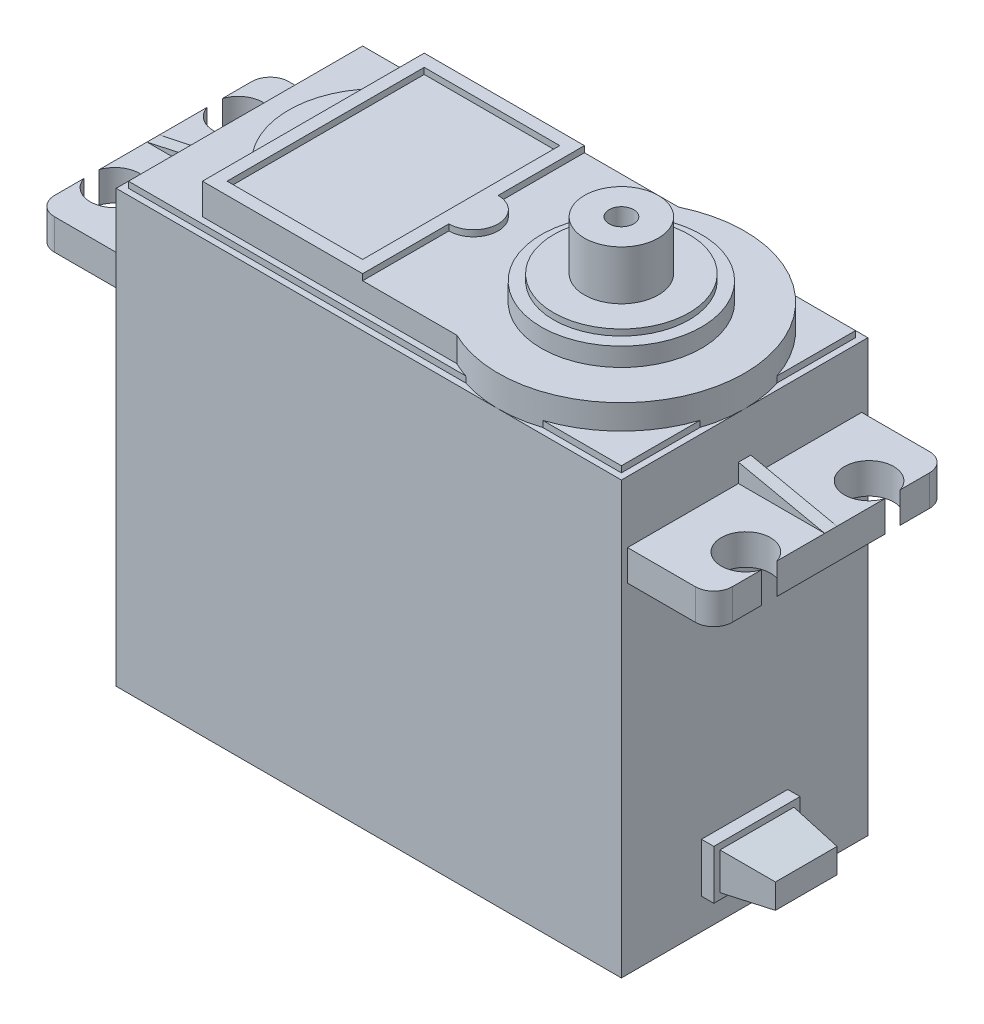
from build123d import *

# Parameters (mm, degrees)
SKETCH1_W            = 41
SKETCH1_H            = 20
BOSS_EXTRUDE1_DEPTH  = 40
CHAMFER1_SIZE        = 2
SKETCH2_R            = 2.25
CUT_EXTRUDE1_DEPTH   = 1
SKETCH3_W            = 19
SKETCH3_H            = 2.5
BOSS_EXTRUDE2_DEPTH  = 7
FILLET1_R            = 1.5
SKETCH4_W            = 7
SKETCH4_H            = 1
BOSS_EXTRUDE3_DEPTH  = 1.5
CUT_EXTRUDE2_DEPTH   = 1
SKETCH6_R            = 2
CUT_EXTRUDE3_DEPTH   = 2.5
FILLET1_OF_MIRROR1_R = 1.5
SKETCH7_W            = 41
SKETCH7_H            = 20
CUT_EXTRUDE4_DEPTH   = 3
SKETCH8_W            = 40
SKETCH8_H            = 19
BOSS_EXTRUDE4_DEPTH  = 0.5
BOSS_EXTRUDE6_DEPTH  = 2.5
SKETCH10_W           = 11
SKETCH10_H           = 16
BOSS_EXTRUDE7_DEPTH  = 0.5
SKETCH11_R           = 6.5
BOSS_EXTRUDE8_DEPTH  = 1.5
SKETCH12_R           = 5.5
BOSS_EXTRUDE9_DEPTH  = 0.5
SKETCH13_R           = 3
BOSS_EXTRUDE10_DEPTH = 4
SKETCH14_R           = 1
CUT_EXTRUDE5_DEPTH   = 8
SKETCH15_W           = 7
SKETCH15_H           = 4
BOSS_EXTRUDE11_DEPTH = 5
SKETCH16_W           = 7
SKETCH16_H           = 4
SKETCH16_W_2         = 6
SKETCH16_H_2         = 3
CUT_EXTRUDE6_DEPTH   = 4
CUT_EXTRUDE7_DEPTH   = 3
CUT_EXTRUDE8_DEPTH   = 7


with BuildPart() as part:
    # Sketch1 → Boss-Extrude1 (new body)
    with BuildSketch(Plane(origin=(0, 0, 0), x_dir=(1, 0, 0), z_dir=(0, 1, 0))):
        Rectangle(SKETCH1_W, SKETCH1_H)
    extrude(amount=BOSS_EXTRUDE1_DEPTH)

    # Chamfer1
    chamfer1_edges = [part.edges().sort_by_distance(p)[0] for p in [
        (0, 0, 10),
        (-20.5, 0, 0),
        (0, 0, -10),
        (20.5, 0, 0),
    ]]
    chamfer(chamfer1_edges, length=CHAMFER1_SIZE)

    # Sketch2 → Cut-Extrude1 (cut)
    with BuildSketch(Plane.XZ):
        with Locations((18.25, 7.75)):
            Circle(SKETCH2_R)
        with Locations((-18.25, 7.75)):
            Circle(SKETCH2_R)
        with Locations((-18.25, -7.75)):
            Circle(SKETCH2_R)
        with Locations((18.25, -7.75)):
            Circle(SKETCH2_R)
    extrude(amount=-CUT_EXTRUDE1_DEPTH, mode=Mode.SUBTRACT)

    # Sketch3 → Boss-Extrude2 (add)
    with BuildSketch(Plane(origin=(20.5, 0, 0), x_dir=(0, 0, -1), z_dir=(1, 0, 0))):
        with Locations((0, 30.75)):
            Rectangle(SKETCH3_W, SKETCH3_H)
    boss_extrude2 = extrude(amount=BOSS_EXTRUDE2_DEPTH)

    # Fillet1
    fillet1_edges = [part.edges().sort_by_distance(p)[0] for p in [
        (27.5, 30.75, 9.5),
        (27.5, 30.75, -9.5),
    ]]
    fillet(fillet1_edges, radius=FILLET1_R)

    # Sketch4 → Boss-Extrude3 (add)
    with BuildSketch(Plane(origin=(0, 32, 0), x_dir=(1, 0, 0), z_dir=(0, 1, 0))):
        with Locations((24, 0)):
            Rectangle(SKETCH4_W, SKETCH4_H)
    boss_extrude3 = extrude(amount=BOSS_EXTRUDE3_DEPTH)

    # Sketch5 → Cut-Extrude2 (cut)
    with BuildSketch(Plane.XY.offset(0.5)):
        Polygon((27.5, 33.5), (27.5, 32), (20.5, 33.5), align=None)
    cut_extrude2 = extrude(amount=-CUT_EXTRUDE2_DEPTH, mode=Mode.SUBTRACT)

    # Sketch6 → Cut-Extrude3 (cut)
    with BuildSketch(Plane(origin=(0, 32, 0), x_dir=(1, 0, 0), z_dir=(0, 1, 0))):
        with Locations((25.6, 5)):
            Circle(SKETCH6_R)
        with Locations((25.6, -5)):
            Circle(SKETCH6_R)
    cut_extrude3 = extrude(amount=-CUT_EXTRUDE3_DEPTH, mode=Mode.SUBTRACT)

    # Mirror1: Boss-Extrude2, Boss-Extrude3, Cut-Extrude2, Cut-Extrude3 across plane
    add(boss_extrude2.mirror(Plane(origin=(0, 0, 0), x_dir=(0, 0, 1), z_dir=(1, 0, 0))))
    add(boss_extrude3.mirror(Plane(origin=(0, 0, 0), x_dir=(0, 0, 1), z_dir=(1, 0, 0))))
    add(cut_extrude2.mirror(Plane(origin=(0, 0, 0), x_dir=(0, 0, 1), z_dir=(1, 0, 0))), mode=Mode.SUBTRACT)
    add(cut_extrude3.mirror(Plane(origin=(0, 0, 0), x_dir=(0, 0, 1), z_dir=(1, 0, 0))), mode=Mode.SUBTRACT)

    # Fillet1 of Mirror1
    fillet1_of_mirror1_edges = [part.edges().sort_by_distance(p)[0] for p in [
        (-27.5, 30.75, 9.5),
        (-27.5, 30.75, -9.5),
    ]]
    fillet(fillet1_of_mirror1_edges, radius=FILLET1_OF_MIRROR1_R)

    # Sketch7 → Cut-Extrude4 (cut)
    with BuildSketch(Plane(origin=(0, 40, 0), x_dir=(1, 0, 0), z_dir=(0, 1, 0))):
        Rectangle(SKETCH7_W, SKETCH7_H)
    extrude(amount=-CUT_EXTRUDE4_DEPTH, mode=Mode.SUBTRACT)

    # Sketch8 → Boss-Extrude4 (add)
    with BuildSketch(Plane(origin=(0, 37, 0), x_dir=(1, 0, 0), z_dir=(0, 1, 0))):
        Rectangle(SKETCH8_W, SKETCH8_H)
    extrude(amount=BOSS_EXTRUDE4_DEPTH)

    # Sketch9 → Boss-Extrude6 (add)
    with BuildSketch(Plane(origin=(0, 37, 0), x_dir=(1, 0, 0), z_dir=(0, 1, 0))):
        with BuildLine():
            Line((6.141101056, 9), (-14.5, 9))
            Line((-14.5, 9), (-14.5, 5))
            ThreePointArc((-14.5, 5), (-16.5, 0), (-14.5, -5))
            Line((-14.5, -5), (-14.5, -9))
            Line((-14.5, -9), (6.141101056, -9))
            ThreePointArc((6.141101056, -9), (20.5, 0), (6.141101056, 9))
        make_face()
    extrude(amount=BOSS_EXTRUDE6_DEPTH)

    # Sketch10 → Boss-Extrude7 (add)
    with BuildSketch(Plane(origin=(0, 39.5, 0), x_dir=(1, 0, 0), z_dir=(0, 1, 0))):
        with BuildLine():
            Line((-14.5, 9), (-1.5, 9))
            Line((-1.5, 9), (-1.5, 2))
            ThreePointArc((-1.5, 2), (0.5, 0), (-1.5, -2))
            Line((-1.5, -2), (-1.5, -9))
            Line((-1.5, -9), (-14.5, -9))
            Line((-14.5, -9), (-14.5, 9))
        make_face()
        with Locations((-8, 0)):
            Rectangle(SKETCH10_W, SKETCH10_H, mode=Mode.SUBTRACT)
    extrude(amount=BOSS_EXTRUDE7_DEPTH)

    # Sketch11 → Boss-Extrude8 (add)
    with BuildSketch(Plane(origin=(0, 39.5, 0), x_dir=(1, 0, 0), z_dir=(0, 1, 0))):
        with Locations((10.5, 0)):
            Circle(SKETCH11_R)
    extrude(amount=BOSS_EXTRUDE8_DEPTH)

    # Sketch12 → Boss-Extrude9 (add)
    with BuildSketch(Plane(origin=(0, 41, 0), x_dir=(1, 0, 0), z_dir=(0, 1, 0))):
        with Locations((10.5, 0)):
            Circle(SKETCH12_R)
    extrude(amount=BOSS_EXTRUDE9_DEPTH)

    # Sketch13 → Boss-Extrude10 (add)
    with BuildSketch(Plane(origin=(0, 41.5, 0), x_dir=(1, 0, 0), z_dir=(0, 1, 0))):
        with Locations((10.5, 0)):
            Circle(SKETCH13_R)
    extrude(amount=BOSS_EXTRUDE10_DEPTH)

    # Sketch14 → Cut-Extrude5 (cut)
    with BuildSketch(Plane(origin=(0, 45.5, 0), x_dir=(1, 0, 0), z_dir=(0, 1, 0))):
        with Locations((10.5, 0)):
            Circle(SKETCH14_R)
    extrude(amount=-CUT_EXTRUDE5_DEPTH, mode=Mode.SUBTRACT)

    # Sketch15 → Boss-Extrude11 (add)
    with BuildSketch(Plane(origin=(20.5, 0, 0), x_dir=(0, 0, -1), z_dir=(1, 0, 0))):
        with Locations((0, 6.5)):
            Rectangle(SKETCH15_W, SKETCH15_H)
    extrude(amount=BOSS_EXTRUDE11_DEPTH)

    # Sketch16 → Cut-Extrude6 (cut)
    with BuildSketch(Plane(origin=(25.5, 0, 0), x_dir=(0, 0, -1), z_dir=(1, 0, 0))):
        with Locations((0, 6.5)):
            Rectangle(SKETCH16_W, SKETCH16_H)
        with Locations((0, 6.5)):
            Rectangle(SKETCH16_W_2, SKETCH16_H_2, mode=Mode.SUBTRACT)
    extrude(amount=-CUT_EXTRUDE6_DEPTH, mode=Mode.SUBTRACT)

    # Sketch17 → Cut-Extrude7 (cut)
    with BuildSketch(Plane.XZ.offset(-5)):
        Polygon((21.5, 3), (25.5, 2.5), (25.5, 3), align=None)
        Polygon((21.5, -3), (25.5, -2.5), (25.5, -3), align=None)
    extrude(amount=-CUT_EXTRUDE7_DEPTH, mode=Mode.SUBTRACT)

    # Sketch18 → Cut-Extrude8 (cut)
    with BuildSketch(Plane(origin=(0, 0, -3.5), x_dir=(-1, 0, 0), z_dir=(0, 0, -1))):
        Polygon((-21.5, 8), (-25.5, 8), (-25.5, 7.5), align=None)
        Polygon((-21.5, 5), (-25.5, 5), (-25.5, 5.5), align=None)
    extrude(amount=-CUT_EXTRUDE8_DEPTH, mode=Mode.SUBTRACT)


solid = part.part
